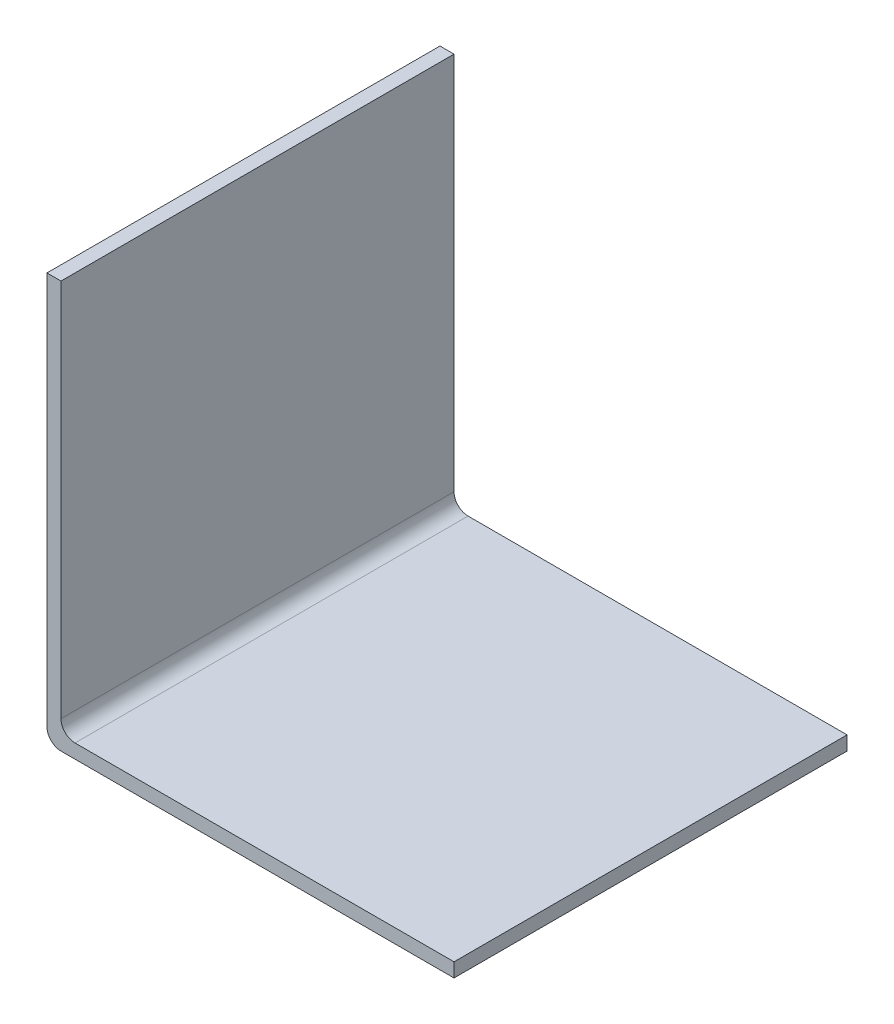
from build123d import *

# Parameters (mm, degrees)
EXTRUDE_1_DEPTH = 28
FILLET_1_R      = 1


with BuildPart() as part:
    # 草图1 → 拉伸-薄壁1 (new body)
    with BuildSketch(Plane.XY):
        Polygon((0, 28), (0, 0), (28, 0), (28, -1), (-1, -1), (-1, 28), align=None)
    extrude(amount=EXTRUDE_1_DEPTH)

    # 圆角1
    fillet_1_edges = [part.edges().sort_by_distance(p)[0] for p in [
        (-1, -1, 14),
        (0, 0, 14),
    ]]
    fillet(fillet_1_edges, radius=FILLET_1_R)


solid = part.part
